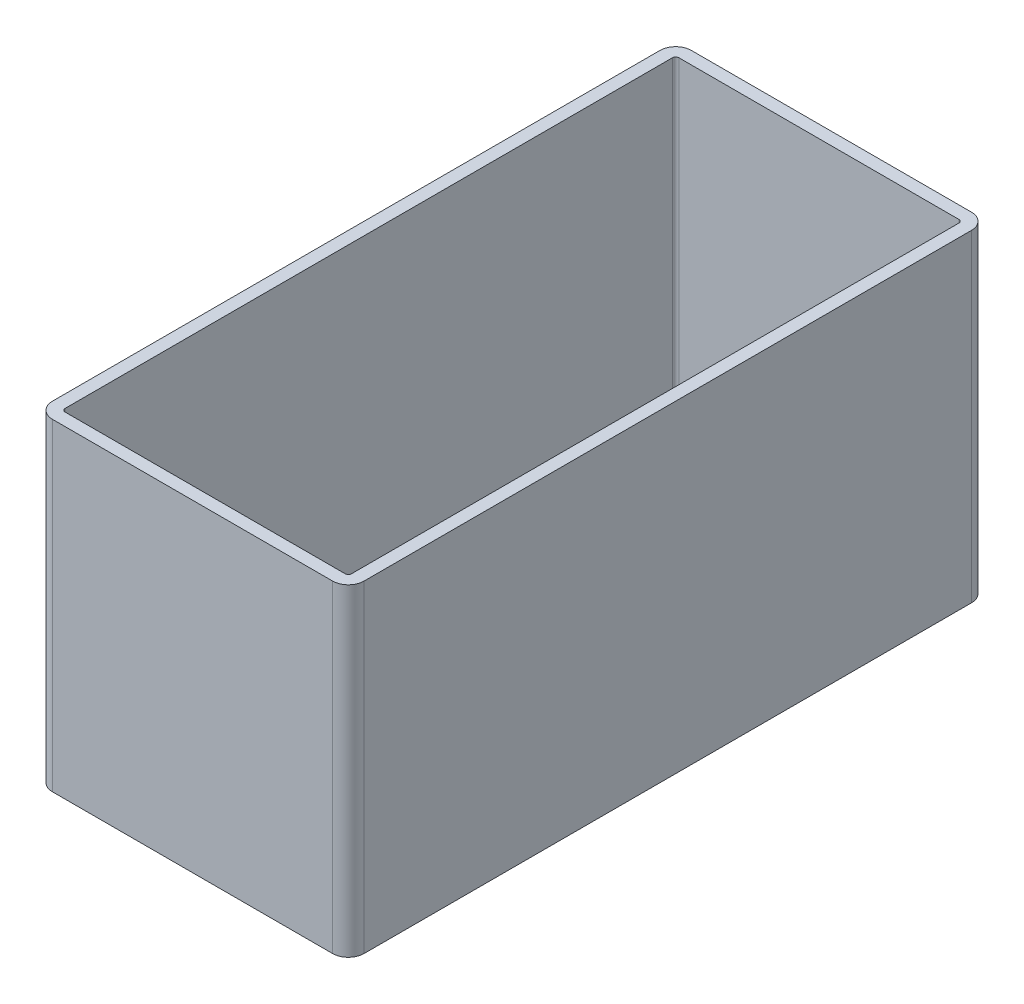
from build123d import *

# Parameters (mm, degrees)
BASES_W            = 19.8
BASES_H            = 40.6
BASE_DEPTH         = 10.25
BASE_F_R           = 1
CUT_EXTRUDE3_DEPTH = 21.5


with BuildPart() as part:
    # BaseS → BASE (new body, symmetric)
    with BuildSketch(Plane(origin=(0, 0, 0), x_dir=(1, 0, 0), z_dir=(0, 1, 0))):
        Rectangle(BASES_W, BASES_H)
    extrude(amount=BASE_DEPTH, both=True)

    # BASE F
    base_f_edges = [part.edges().sort_by_distance(p)[0] for p in [
        (9.9, 0, 20.3),
        (-9.9, 0, 20.3),
        (-9.9, 0, -20.3),
        (9.9, 0, -20.3),
    ]]
    fillet(base_f_edges, radius=BASE_F_R)

    # PocketS → Cut-Extrude3 (cut, through all)
    with BuildSketch(Plane(origin=(0, 10.25, 0), x_dir=(1, 0, 0), z_dir=(0, 1, 0))):
        with BuildLine():
            Line((8.9, 19.5), (-8.9, 19.5))
            ThreePointArc((-8.9, 19.5), (-9.041421356, 19.441421356), (-9.1, 19.3))
            Line((-9.1, 19.3), (-9.1, -19.3))
            ThreePointArc((-9.1, -19.3), (-9.041421356, -19.441421356), (-8.9, -19.5))
            Line((-8.9, -19.5), (8.9, -19.5))
            ThreePointArc((8.9, -19.5), (9.041421356, -19.441421356), (9.1, -19.3))
            Line((9.1, -19.3), (9.1, 19.3))
            ThreePointArc((9.1, 19.3), (9.041421356, 19.441421356), (8.9, 19.5))
        make_face()
    extrude(amount=-CUT_EXTRUDE3_DEPTH, mode=Mode.SUBTRACT)


solid = part.part
